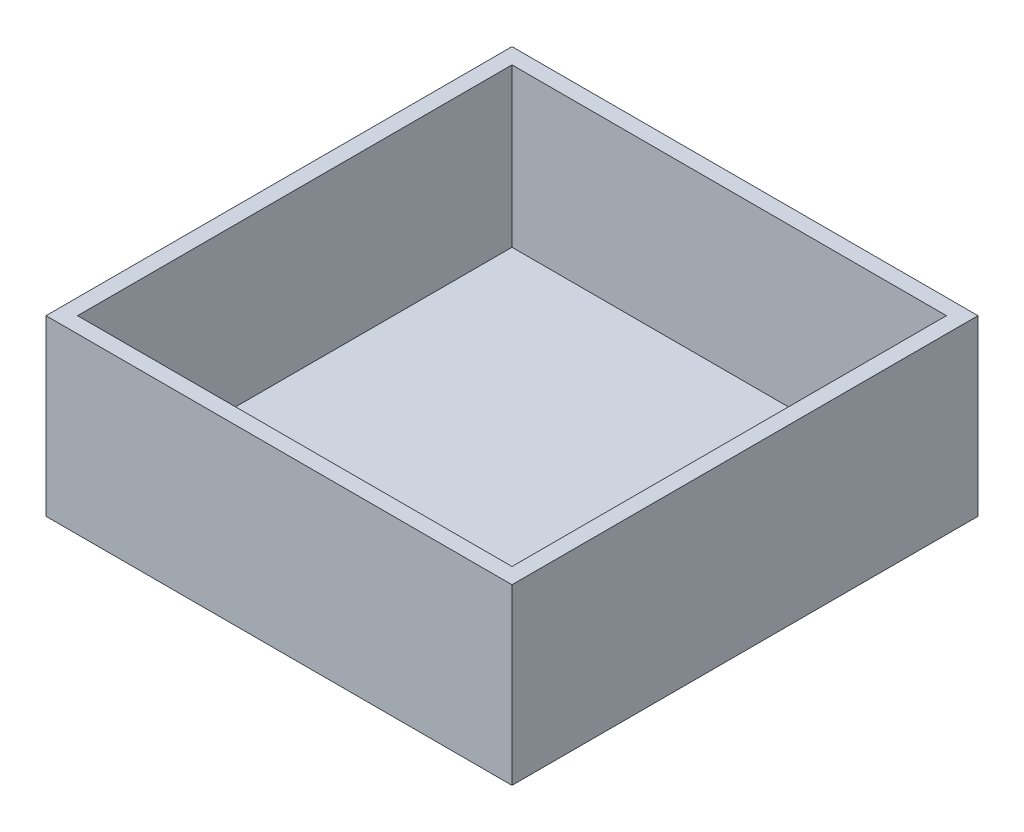
from build123d import *

# Parameters (mm, degrees)
SKETCH1_W           = 59
SKETCH1_H           = 59
SKETCH1_W_2         = 55
SKETCH1_H_2         = 55
BOSS_EXTRUDE1_DEPTH = 20
SKETCH2_W           = 59
SKETCH2_H           = 59
BOSS_EXTRUDE2_DEPTH = 2


with BuildPart() as part:
    # Sketch1 → Boss-Extrude1 (new body)
    with BuildSketch(Plane(origin=(0, 0, 0), x_dir=(1, 0, 0), z_dir=(0, 1, 0))):
        with Locations((29.5, -29.5)):
            Rectangle(SKETCH1_W, SKETCH1_H)
        with Locations((29.5, -29.5)):
            Rectangle(SKETCH1_W_2, SKETCH1_H_2, mode=Mode.SUBTRACT)
    extrude(amount=BOSS_EXTRUDE1_DEPTH)

    # Sketch2 → Boss-Extrude2 (add)
    with BuildSketch(Plane.XZ):
        with Locations((29.5, 29.5)):
            Rectangle(SKETCH2_W, SKETCH2_H)
    extrude(amount=BOSS_EXTRUDE2_DEPTH)


solid = part.part
